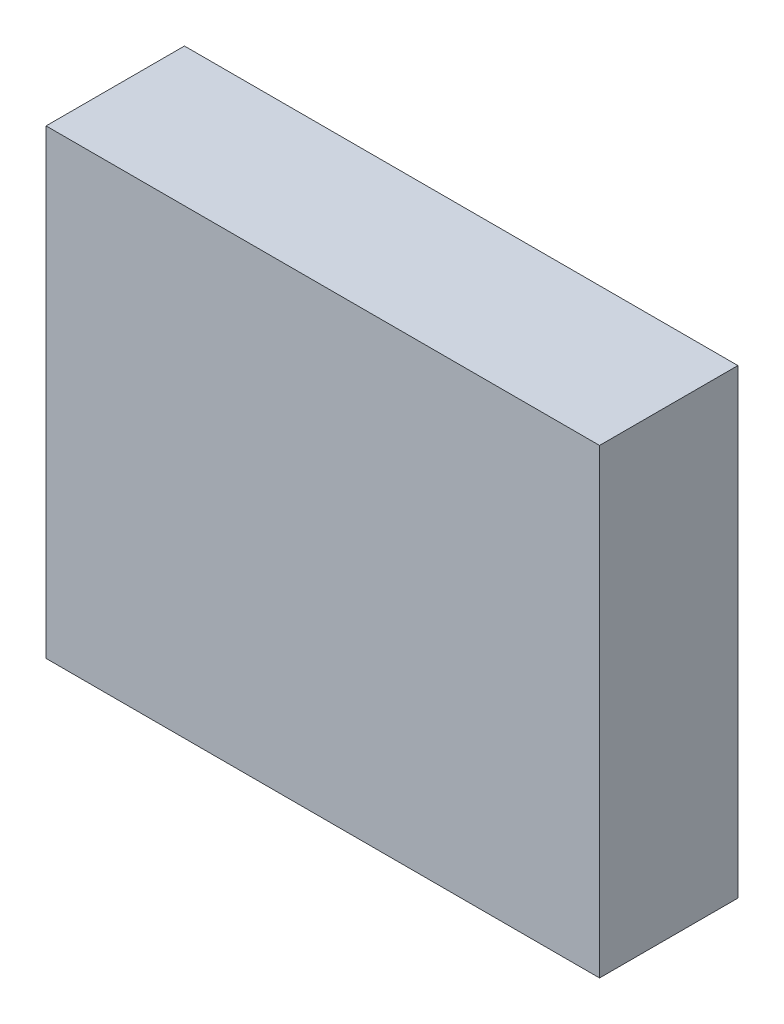
from build123d import *

# Parameters (mm, degrees)
SKETCH1_W           = 12
SKETCH1_H           = 10
BOSS_EXTRUDE1_DEPTH = 3


with BuildPart() as part:
    # Sketch1 → Boss-Extrude1 (new body)
    with BuildSketch(Plane.XY):
        Rectangle(SKETCH1_W, SKETCH1_H)
    extrude(amount=BOSS_EXTRUDE1_DEPTH)


solid = part.part
